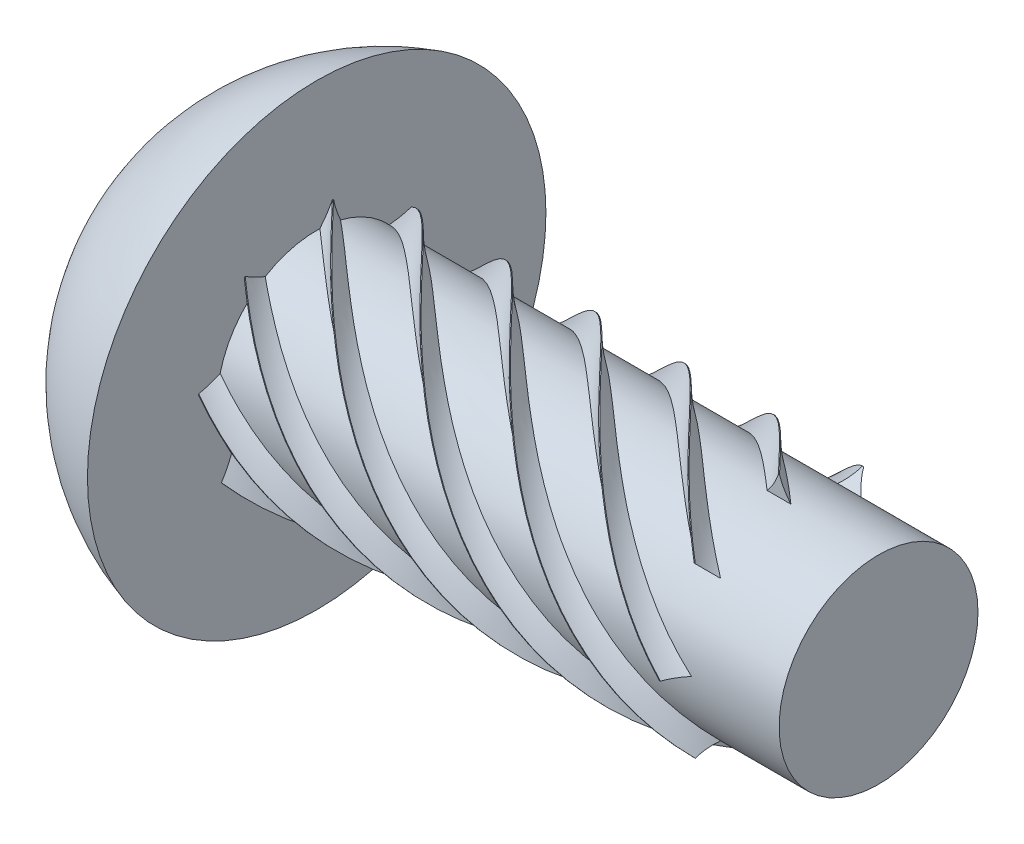
from build123d import *

# Parameters (mm, degrees)
SKETCH4_R          = 2.6924
SKETCH4_R_2        = 2.2479
CUT_EXTRUDE1_DEPTH = 10.7188
SWEEP1_PITCH       = 16.1544
SWEEP1_HEIGHT      = 10.7188
SWEEP1_RADIUS      = 2.6924
SWEEP1_START_ANGLE = -90
CIRPATTERN1_COUNT  = 8


with BuildPart() as part:
    # Sketch2 → Revolve1 (revolve)
    with BuildSketch(Plane.XY, mode=Mode.PRIVATE) as revolve1_sk:
        with BuildLine():
            Line((8.2931, 0), (8.2931, 2.2479))
            Line((8.2931, 2.2479), (6.3119, 2.2479))
            Line((6.3119, 2.2479), (6.3119, 2.6924))
            Line((6.3119, 2.6924), (-4.4069, 2.6924))
            Line((-4.4069, 2.6924), (-4.4069, 5.1816))
            ThreePointArc((-4.4069, 5.1816), (-7.2136, 3.2385), (-8.2931, 0))
            Line((-8.2931, 0), (8.2931, 0))
        make_face()
    revolve(revolve1_sk.sketch.rotate(Axis((8.2931, 0, 0), (-1, 0, 0)), 90), axis=Axis((8.2931, 0, 0), (-1, 0, 0)))

    # Sketch4 → Cut-Extrude1 (cut)
    with BuildSketch(Plane(origin=(6.3119, 0, 0), x_dir=(0, 0, -1), z_dir=(1, 0, 0))):
        Circle(SKETCH4_R)
        Circle(SKETCH4_R_2, mode=Mode.SUBTRACT)
    extrude(amount=-CUT_EXTRUDE1_DEPTH, mode=Mode.SUBTRACT)

    # Sweep1: sweep along a helix
    with BuildLine() as sweep1_path:
        add(Helix(SWEEP1_PITCH, SWEEP1_HEIGHT, SWEEP1_RADIUS, center=(6.3119, 0, 0), direction=(-1, 0, 0), mode=Mode.PRIVATE).rotate(Axis((6.3119, 0, 0), (-1, 0, 0)), SWEEP1_START_ANGLE))
    with BuildLine() as sweep1_axis:
        Line((6.3119, 0, 0), (-4.4069, 0, 0))
    # Sketch6 → Sweep1 (sweep)
    with BuildSketch(Plane.XY):
        with BuildLine():
            Line((6.055267805, 2.6924), (6.029867805, 2.6924))
            ThreePointArc((6.029867805, 2.6924), (5.923548753, 2.45745), (5.773235611, 2.2479))
            Line((5.773235611, 2.2479), (6.3119, 2.2479))
            ThreePointArc((6.3119, 2.2479), (6.161586857, 2.45745), (6.055267805, 2.6924))
        make_face()
    sweep1 = sweep(path=sweep1_path.line, binormal=sweep1_axis.edges()[0])

    # CirPattern1: Sweep1 ×8 about axis
    cirpattern1_axis = Axis((0, 0, 0), (-1, 0, 0))
    for i in range(1, CIRPATTERN1_COUNT):
        add(sweep1.rotate(cirpattern1_axis, i * 360 / CIRPATTERN1_COUNT))


solid = part.part
